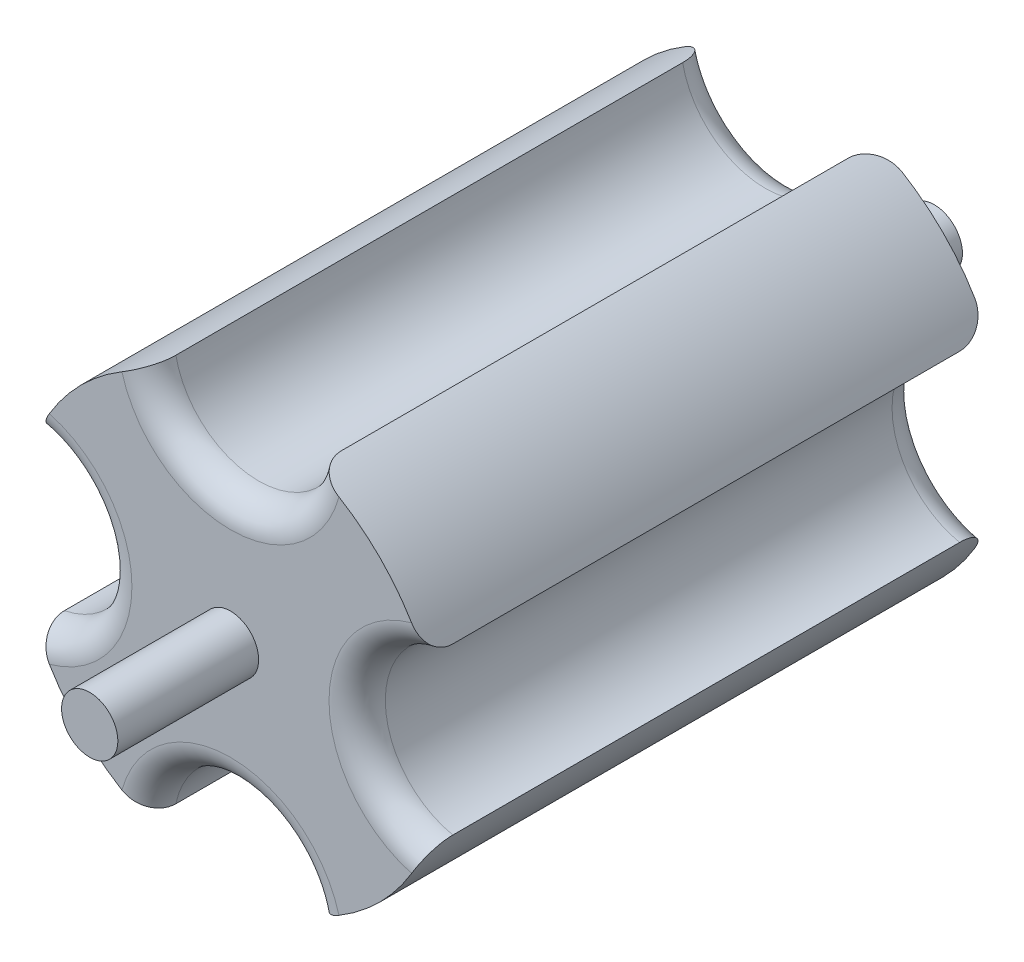
from build123d import *

# Parameters (mm, degrees)
SKETCH2_R           = 19.05
BOSS_EXTRUDE1_DEPTH = 50.8
SKETCH5_R           = 7.62
CUT_EXTRUDE2_DEPTH  = 51.8
SKETCH6_R           = 2.54
BOSS_EXTRUDE2_DEPTH = 12.7
SKETCH7_R           = 2.54
BOSS_EXTRUDE3_DEPTH = 12.7
FILLET1_R           = 2.54


with BuildPart() as part:
    # Sketch2 → Boss-Extrude1 (new body)
    with BuildSketch(Plane.XY):
        Circle(SKETCH2_R)
    extrude(amount=BOSS_EXTRUDE1_DEPTH)

    # Sketch5 → Cut-Extrude2 (cut, through all)
    with BuildSketch(Plane.XY.offset(50.8)):
        with Locations((0, 19.05)):
            Circle(SKETCH5_R)
        with Locations((19.05, 0)):
            Circle(SKETCH5_R)
        with Locations((0, -19.05)):
            Circle(SKETCH5_R)
        with Locations((-19.05, 0)):
            Circle(SKETCH5_R)
    extrude(amount=-CUT_EXTRUDE2_DEPTH, mode=Mode.SUBTRACT)

    # Sketch6 → Boss-Extrude2 (add)
    with BuildSketch(Plane.XY.offset(50.8)):
        Circle(SKETCH6_R)
    extrude(amount=BOSS_EXTRUDE2_DEPTH)

    # Sketch7 → Boss-Extrude3 (add)
    with BuildSketch(Plane(origin=(0, 0, 0), x_dir=(-1, 0, 0), z_dir=(0, 0, -1))):
        Circle(SKETCH7_R)
    extrude(amount=BOSS_EXTRUDE3_DEPTH)

    # Fillet1
    fillet1_edges = [part.edges().sort_by_distance(p)[0] for p in [
        (0, 11.43, 50.8),
        (0, 11.43, 0),
        (11.43, 0, 50.8),
        (11.43, 0, 0),
        (0, -11.43, 50.8),
        (0, -11.43, 0),
        (-11.43, 0, 50.8),
        (-11.43, 0, 0),
    ]]
    fillet(fillet1_edges, radius=FILLET1_R)


solid = part.part
